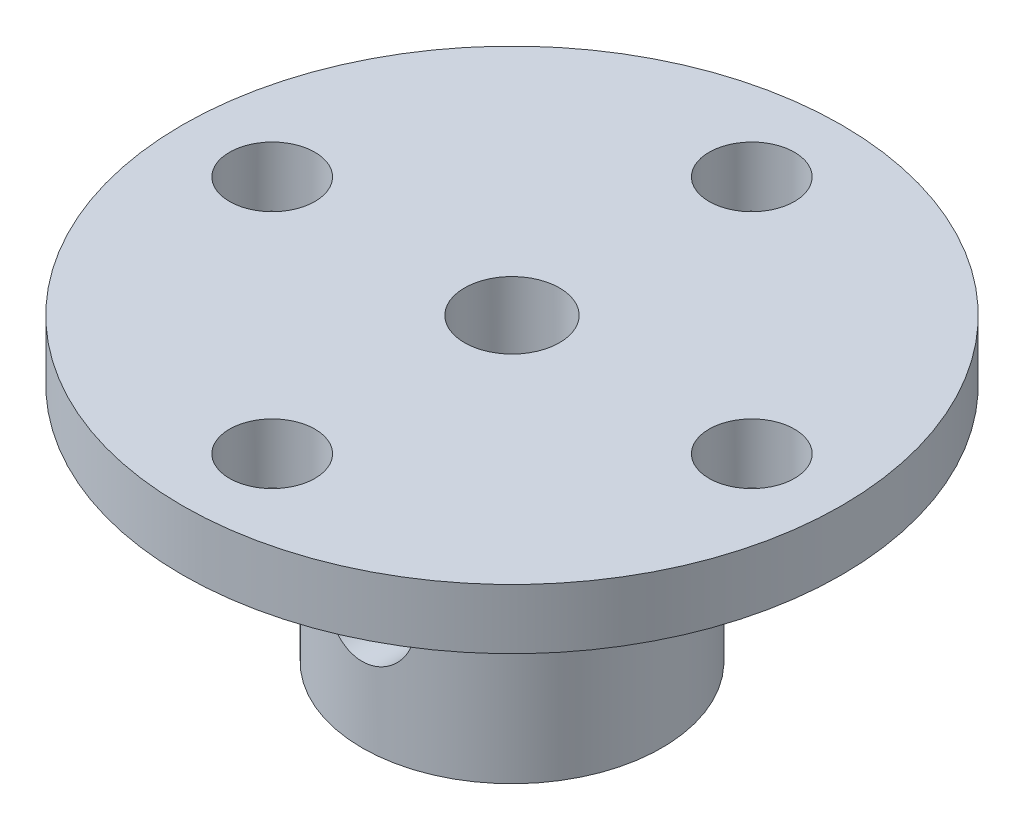
from build123d import *

# Parameters (mm, degrees)
SKETCH1_R               = 11
BOSS_EXTRUDE1_DEPTH     = 2
SKETCH2_R               = 5
BOSS_EXTRUDE2_DEPTH     = 8
SKETCH3_R               = 1.585
CUT_EXTRUDE1_DEPTH      = 11
SKETCH4_R               = 1.425
CUT_EXTRUDE2_DEPTH      = 2
CIRPATTERN1_COUNT       = 4
SKETCH5_R               = 1.5
CUT_EXTRUDE3_DEPTH      = 12
CUT_EXTRUDE3_DEPTH_BACK = 12


with BuildPart() as part:
    # Sketch1 → Boss-Extrude1 (new body)
    with BuildSketch(Plane(origin=(0, 0, 0), x_dir=(1, 0, 0), z_dir=(0, 1, 0))):
        Circle(SKETCH1_R)
    extrude(amount=BOSS_EXTRUDE1_DEPTH)

    # Sketch2 → Boss-Extrude2 (add)
    with BuildSketch(Plane(origin=(0, 0, 0), x_dir=(1, 0, 0), z_dir=(0, 1, 0))):
        Circle(SKETCH2_R)
    extrude(amount=-BOSS_EXTRUDE2_DEPTH)

    # Sketch3 → Cut-Extrude1 (cut, through all)
    with BuildSketch(Plane(origin=(0, 2, 0), x_dir=(-1, 0, 0), z_dir=(0, -1, 0))):
        Circle(SKETCH3_R)
    extrude(amount=CUT_EXTRUDE1_DEPTH, mode=Mode.SUBTRACT)

    # Sketch4 → Cut-Extrude2 (cut)
    with BuildSketch(Plane(origin=(0, 2, 0), x_dir=(1, 0, 0), z_dir=(0, 1, 0))):
        with Locations((0, 8)):
            Circle(SKETCH4_R)
    cut_extrude2 = extrude(amount=-CUT_EXTRUDE2_DEPTH, mode=Mode.SUBTRACT)

    # CirPattern1: Cut-Extrude2 ×4 about axis
    cirpattern1_axis = Axis((0, 0, 0), (0, 1, 0))
    for i in range(1, CIRPATTERN1_COUNT):
        add(cut_extrude2.rotate(cirpattern1_axis, i * 360 / CIRPATTERN1_COUNT), mode=Mode.SUBTRACT)

    # Sketch5 → Cut-Extrude3 (cut, two sides)
    with BuildSketch(Plane.XY) as cut_extrude3_sk:
        with Locations((0, -4)):
            Circle(SKETCH5_R)
    extrude(amount=CUT_EXTRUDE3_DEPTH, mode=Mode.SUBTRACT)
    extrude(cut_extrude3_sk.sketch, amount=-CUT_EXTRUDE3_DEPTH_BACK, mode=Mode.SUBTRACT)


solid = part.part
